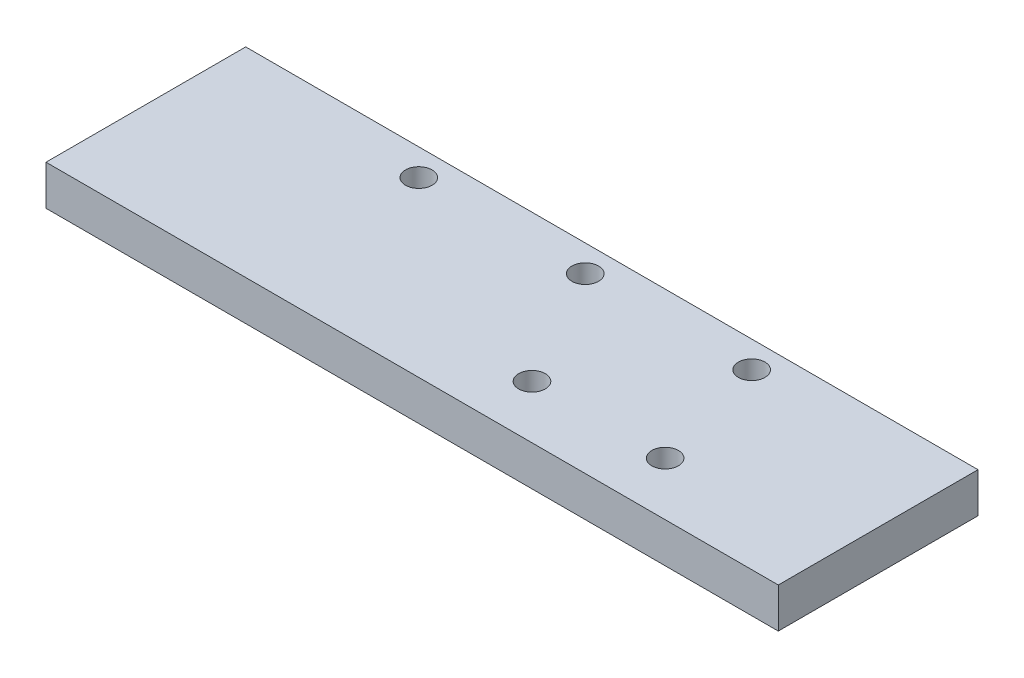
from build123d import *

# Parameters (mm, degrees)
SKETCH1_W           = 110
SKETCH1_H           = 30
BOSS_EXTRUDE1_DEPTH = 6
SKETCH2_R           = 2
CUT_EXTRUDE1_DEPTH  = 10


with BuildPart() as part:
    # Sketch1 → Boss-Extrude1 (new body)
    with BuildSketch(Plane(origin=(0, 0, 0), x_dir=(1, 0, 0), z_dir=(0, 1, 0))):
        with Locations((-47.510460251, 50.167364017)):
            Rectangle(SKETCH1_W, SKETCH1_H)
    extrude(amount=BOSS_EXTRUDE1_DEPTH)

    # Sketch2 → Cut-Extrude1 (cut)
    with BuildSketch(Plane.XZ):
        with Locations((-72.510460251, -61.167364017)):
            Circle(SKETCH2_R)
        with Locations((-47.510460251, -61.167364017)):
            Circle(SKETCH2_R)
        with Locations((-22.510460251, -61.167364017)):
            Circle(SKETCH2_R)
        with Locations((-17.510460251, -43.167364017)):
            Circle(SKETCH2_R)
        with Locations((-37.510460251, -43.167364017)):
            Circle(SKETCH2_R)
    extrude(amount=-CUT_EXTRUDE1_DEPTH, mode=Mode.SUBTRACT)


solid = part.part
